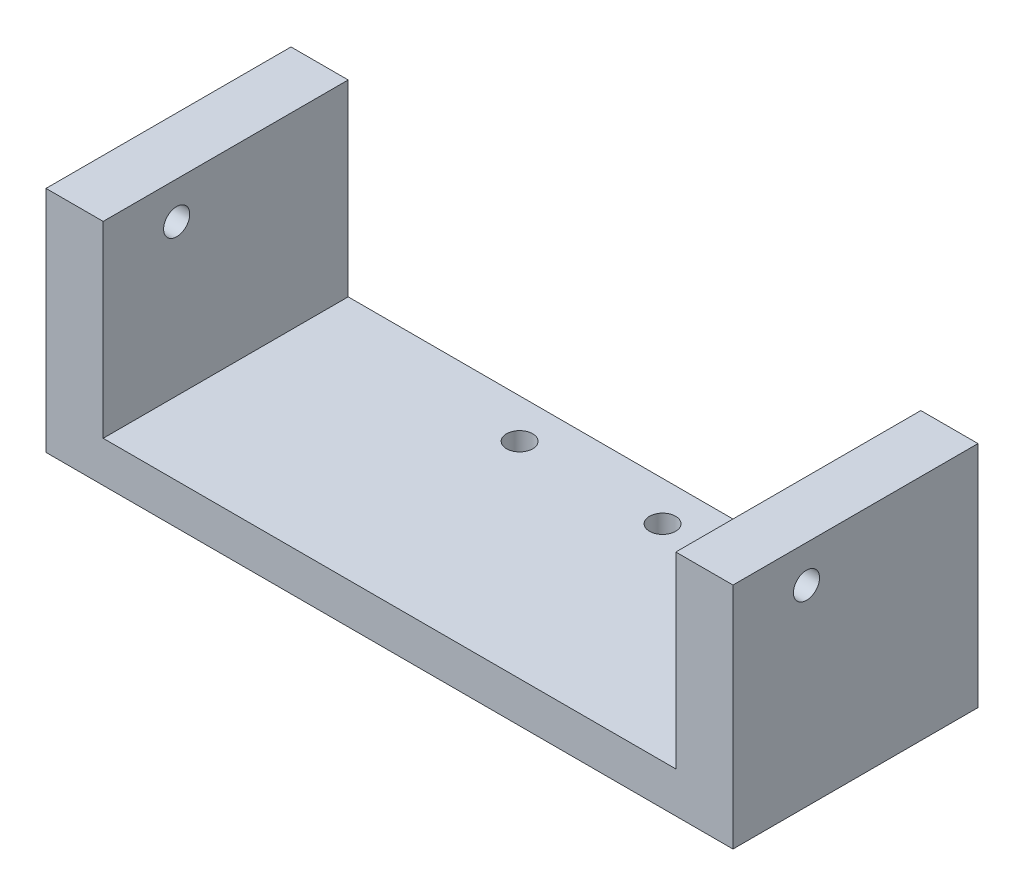
from build123d import *

# Parameters (mm, degrees)
SKETCH1_W           = 95.7
SKETCH1_H           = 100
SKETCH1_R           = 1.6
BOSS_EXTRUDE1_DEPTH = 3
SKETCH2_W           = 84.114636839
SKETCH2_H           = 30
SKETCH2_R           = 1.6
BOSS_EXTRUDE2_DEPTH = 5
SKETCH3_W           = 7
SKETCH3_H           = 30
BOSS_EXTRUDE3_DEPTH = 23
SKETCH4_R           = 1.6
CUT_EXTRUDE1_DEPTH  = 114
SKETCH5_W           = 95.7
SKETCH5_H           = 6
CUT_EXTRUDE2_DEPTH  = 114


with BuildPart() as part:
    # Sketch1 → Boss-Extrude1 (new body, symmetric)
    with BuildSketch(Plane(origin=(0, 0, 0), x_dir=(1, 0, 0), z_dir=(0, 1, 0))):
        Rectangle(SKETCH1_W, SKETCH1_H)
        with Locations((-8.75, 45.181367204)):
            Circle(SKETCH1_R, mode=Mode.SUBTRACT)
        with Locations((8.75, 45.181367204)):
            Circle(SKETCH1_R, mode=Mode.SUBTRACT)
        with Locations((0, -46)):
            Circle(SKETCH1_R, mode=Mode.SUBTRACT)
    extrude(amount=BOSS_EXTRUDE1_DEPTH, both=True)

    # Sketch2 → Boss-Extrude2 (add)
    with BuildSketch(Plane(origin=(0, 3, 0), x_dir=(1, 0, 0), z_dir=(0, 1, 0))):
        with Locations((0.497719744, 35)):
            Rectangle(SKETCH2_W, SKETCH2_H)
        with Locations((-8.75, 45.181367204)):
            Circle(SKETCH2_R, mode=Mode.SUBTRACT)
        with Locations((8.75, 45.181367204)):
            Circle(SKETCH2_R, mode=Mode.SUBTRACT)
        with Locations((0.497719744, 35)):
            Rectangle(SKETCH2_W, SKETCH2_H)
        with Locations((-8.75, 45.181367204)):
            Circle(SKETCH2_R, mode=Mode.SUBTRACT)
        with Locations((8.75, 45.181367204)):
            Circle(SKETCH2_R, mode=Mode.SUBTRACT)
    extrude(amount=BOSS_EXTRUDE2_DEPTH)

    # Sketch3 → Boss-Extrude3 (add)
    with BuildSketch(Plane(origin=(0, 8, 0), x_dir=(1, 0, 0), z_dir=(0, 1, 0))):
        with Locations((-38.059598675, 35)):
            Rectangle(SKETCH3_W, SKETCH3_H)
        with Locations((39.055038164, 35)):
            Rectangle(SKETCH3_W, SKETCH3_H)
    extrude(amount=BOSS_EXTRUDE3_DEPTH)

    # Sketch4 → Cut-Extrude1 (cut)
    with BuildSketch(Plane.ZY.offset(41.559598675)):
        with Locations((-29, 26.474830264)):
            Circle(SKETCH4_R)
    extrude(amount=-CUT_EXTRUDE1_DEPTH, mode=Mode.SUBTRACT)

    # Sketch5 → Cut-Extrude2 (cut)
    with BuildSketch(Plane.XY.offset(50)):
        Rectangle(SKETCH5_W, SKETCH5_H)
    extrude(amount=-CUT_EXTRUDE2_DEPTH, mode=Mode.SUBTRACT)


solid = part.part
